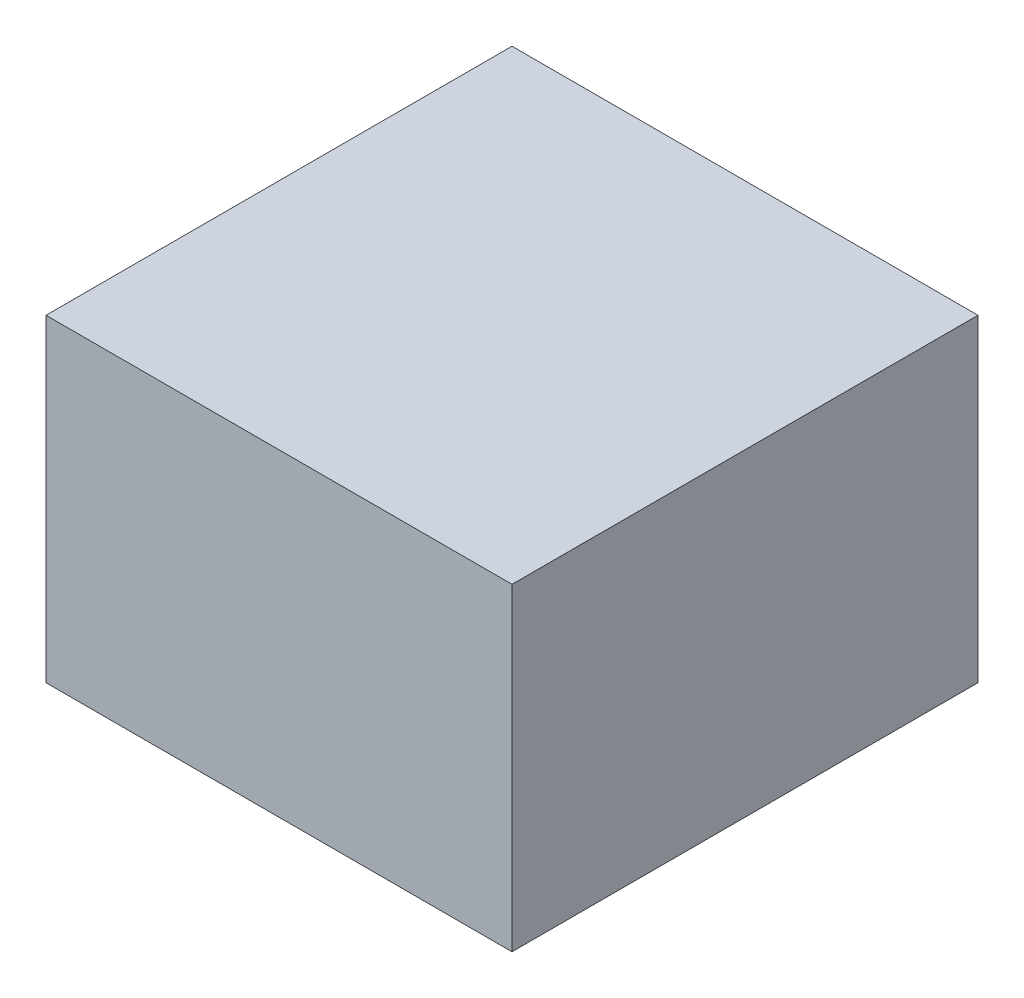
from build123d import *

# Parameters (mm, degrees)
SKETCH1_W           = 65.6
SKETCH1_H           = 65.6
BOSS_EXTRUDE1_DEPTH = 22.4


with BuildPart() as part:
    # Sketch1 → Boss-Extrude1 (new body, symmetric)
    with BuildSketch(Plane(origin=(0, 0, 0), x_dir=(1, 0, 0), z_dir=(0, 1, 0))):
        Rectangle(SKETCH1_W, SKETCH1_H)
    extrude(amount=BOSS_EXTRUDE1_DEPTH, both=True)


solid = part.part
